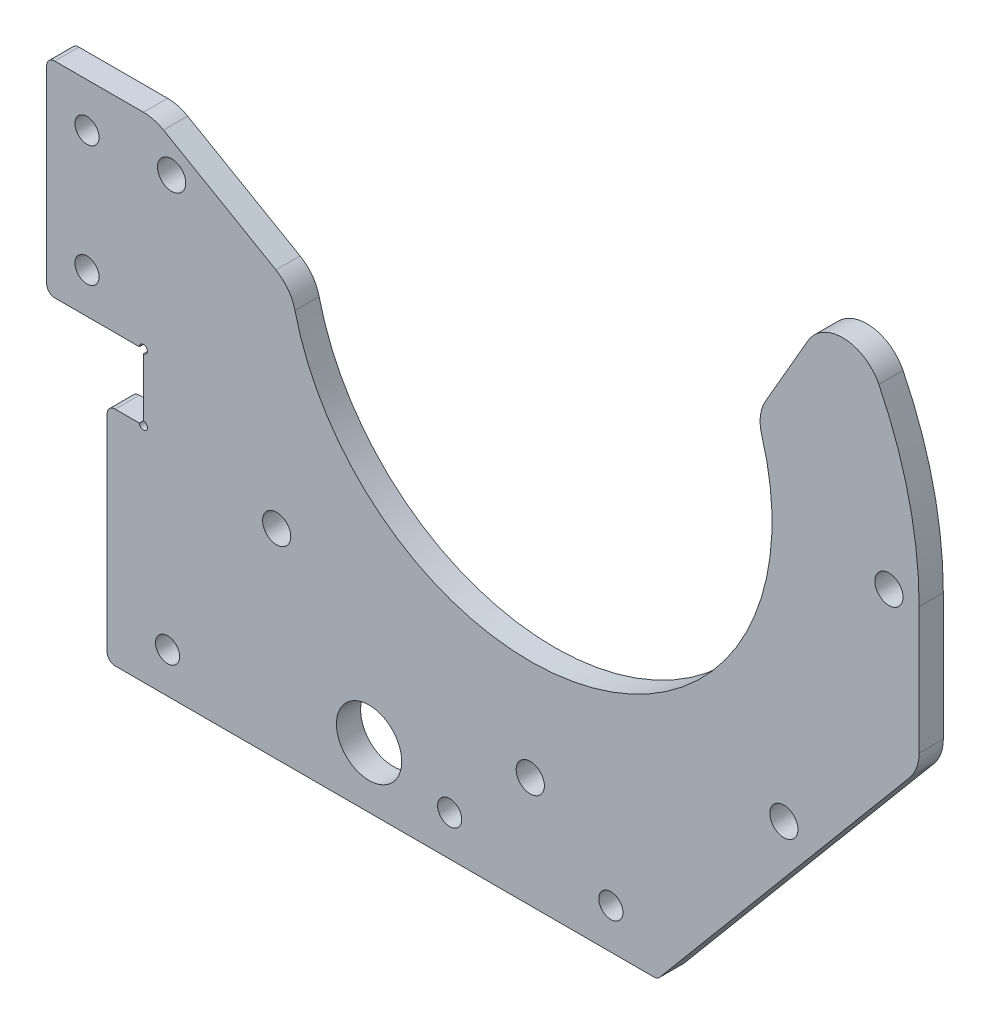
from build123d import *

# Parameters (mm, degrees)
SKETCH_1_R          = 1.5
SKETCH_1_R_2        = 1.75
EXTRUDE_1_DEPTH     = 3
FILLET_1_R          = 5
SKETCH_3_R          = 0.5
CUT_EXTRUDE_1_DEPTH = 10
SKETCH_4_R          = 4.05
CUT_EXTRUDE_2_DEPTH = 10
FILLET_2_R          = 1


with BuildPart() as part:
    # 草图1 → 凸台-拉伸1 (new body)
    with BuildSketch(Plane.XY):
        with BuildLine():
            Line((48.25, -17.561563803), (48.25, 0))
            ThreePointArc((48.25, 0), (45.781945765, 15.234038926), (38.630271835, 28.909593528))
            Line((38.630271835, 28.909593528), (28.062669438, 10.605969263))
            ThreePointArc((28.062669438, 10.605969263), (7.764571353, -28.977774789), (-29.605969263, -4.846295906))
            Line((-29.605969263, -4.846295906), (-46.660254038, 5))
            Line((-46.660254038, 5), (-60, 5))
            Line((-60, 5), (-60, -20.45))
            Line((-60, -20.45), (-48, -20.45))
            Line((-48, -20.45), (-48, -28.65))
            Line((-48, -28.65), (-52.5, -28.65))
            Line((-52.5, -28.65), (-52.5, -56.25))
            Line((-52.5, -56.25), (-29.605969263, -56.25))
            Line((-29.605969263, -56.25), (15.786547457, -56.25))
            Line((15.786547457, -56.25), (48.25, -17.561563803))
        make_face()
        with Locations((-45, -51.25)):
            Circle(SKETCH_1_R, mode=Mode.SUBTRACT)
        with Locations((-10, -51.25)):
            Circle(SKETCH_1_R, mode=Mode.SUBTRACT)
        with Locations((-55, -15.45)):
            Circle(SKETCH_1_R, mode=Mode.SUBTRACT)
        with Locations((-31.466251763, -31.466251763)):
            Circle(SKETCH_1_R_2, mode=Mode.SUBTRACT)
        with Locations((10, -51.25)):
            Circle(SKETCH_1_R, mode=Mode.SUBTRACT)
        with Locations((0, -42.5)):
            Circle(SKETCH_1_R_2, mode=Mode.SUBTRACT)
        with Locations((31.466251763, -31.466251763)):
            Circle(SKETCH_1_R_2, mode=Mode.SUBTRACT)
        with Locations((-55, -0.45)):
            Circle(SKETCH_1_R, mode=Mode.SUBTRACT)
        with Locations((-44.5, 0)):
            Circle(SKETCH_1_R_2, mode=Mode.SUBTRACT)
        with Locations((44.5, 0)):
            Circle(SKETCH_1_R_2, mode=Mode.SUBTRACT)
    extrude(amount=EXTRUDE_1_DEPTH)

    # 圆角1
    fillet_1_edges = [part.edges().sort_by_distance(p)[0] for p in [
        (48.25, -17.561563803, 1.5),
        (-46.660254038, 5, 1.5),
        (-29.605969263, -4.846295906, 1.5),
        (28.062669438, 10.605969263, 1.5),
        (38.630271835, 28.909593528, 1.5),
    ]]
    fillet(fillet_1_edges, radius=FILLET_1_R)

    # 草图3 → 切除-拉伸1 (cut)
    with BuildSketch(Plane(origin=(0, 0, 0), x_dir=(-1, 0, 0), z_dir=(0, 0, -1))):
        with Locations((48, -20.45)):
            Circle(SKETCH_3_R)
        with Locations((48, -28.65)):
            Circle(SKETCH_3_R)
    extrude(amount=-CUT_EXTRUDE_1_DEPTH, mode=Mode.SUBTRACT)

    # 草图4 → 切除-拉伸2 (cut)
    with BuildSketch(Plane.XY.offset(3)):
        with Locations((-20, -48.75)):
            Circle(SKETCH_4_R)
    extrude(amount=-CUT_EXTRUDE_2_DEPTH, mode=Mode.SUBTRACT)

    # 圆角2
    fillet_2_edges = [part.edges().sort_by_distance(p)[0] for p in [
        (15.786547457, -56.25, 1.5),
        (-52.5, -56.25, 1.5),
        (-52.5, -28.65, 1.5),
        (-60, -20.45, 1.5),
        (-60, 5, 1.5),
    ]]
    fillet(fillet_2_edges, radius=FILLET_2_R)


solid = part.part
